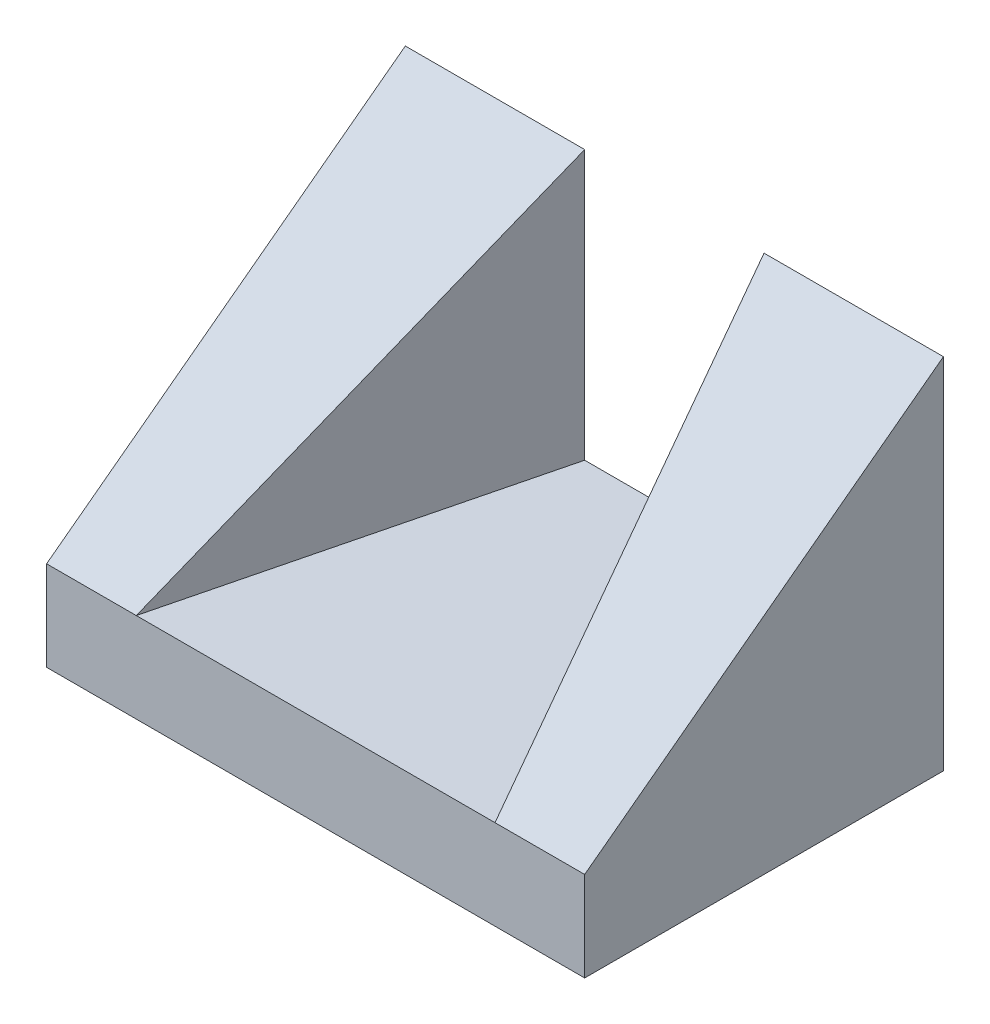
from build123d import *

# Parameters (mm, degrees)
BOSS_EXTRUDE1_DEPTH     = 10000
BOSS_EXTRUDE2_DEPTH     = 40000
CUT_EXTRUDE1_DEPTH      = 82463.112512353
CUT_EXTRUDE1_DEPTH_BACK = 82463.112512353


with BuildPart() as part:
    # Sketch1 → Boss-Extrude1 (new body)
    with BuildSketch(Plane(origin=(0, 0, 0), x_dir=(1, 0, 0), z_dir=(0, 1, 0))):
        Polygon((20000, 40000), (10000, 0), (50000, 0), (40000, 40000), align=None)
    extrude(amount=BOSS_EXTRUDE1_DEPTH)

    # Sketch1_3 → Boss-Extrude2 (add)
    with BuildSketch(Plane(origin=(0, 0, 0), x_dir=(1, 0, 0), z_dir=(0, 1, 0))):
        Polygon((0, 40000), (0, 0), (10000, 0), (20000, 40000), align=None)
        Polygon((40000, 40000), (50000, 0), (60000, 0), (60000, 40000), align=None)
    extrude(amount=BOSS_EXTRUDE2_DEPTH)

    # Sketch3 → Cut-Extrude1 (cut, two sides: drawn at the far end of the back side and taken through both)
    with BuildSketch(Plane(origin=(60000, 0, 0), x_dir=(0, 0, -1), z_dir=(1, 0, 0)).offset(-CUT_EXTRUDE1_DEPTH_BACK)):
        Polygon((130517.667991878, 107888.250993909), (40000, 40000), (0, 10000), (-90517.667991878, -57888.250993909), (-226294.169979695, 123147.084989848), (-5258.833995939, 288923.586977665), align=None)
    extrude(amount=CUT_EXTRUDE1_DEPTH + CUT_EXTRUDE1_DEPTH_BACK, mode=Mode.SUBTRACT)


solid = part.part
